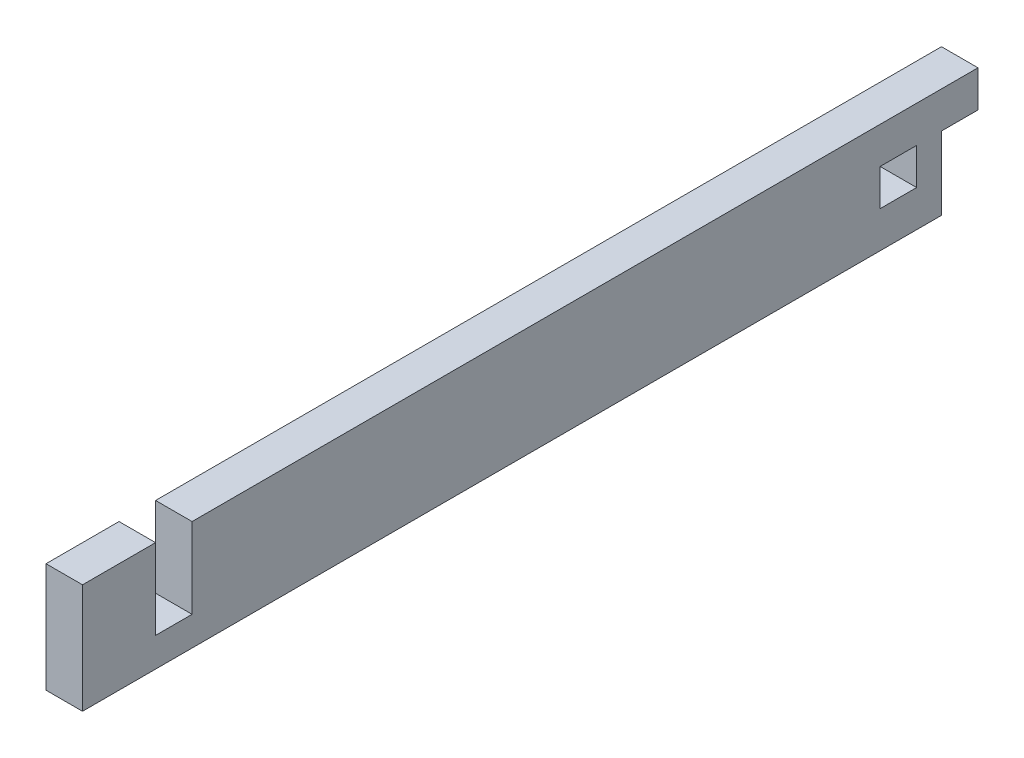
from build123d import *

# Parameters (mm, degrees)
BOSS_EXTRUDE1_DEPTH = 19.05
SKETCH2_W           = 43.434
SKETCH2_H           = 13.97
MOTOR_HOLE_DEPTH    = 19.05
SKETCH3_W           = 6.35
SKETCH3_H           = 12.7
CUT_EXTRUDE2_DEPTH  = 36.941
SKETCH5_W           = 6.35
SKETCH5_H           = 13.97
SKETCH5_H_2         = 6.35
CUT_EXTRUDE6_DEPTH  = 36.941
SKETCH7_W           = 45.976326486
SKETCH7_H           = 159.787423729
CUT_EXTRUDE7_DEPTH  = 20.05


with BuildPart() as part:
    # Sketch1 → Boss-Extrude1 (new body)
    with BuildSketch(Plane(origin=(0, 0, 0), x_dir=(1, 0, 0), z_dir=(0, 1, 0))):
        Polygon((-10.033, 66.167), (-11.6205, 66.167), (-11.6205, 76.835), (-17.9705, 76.835), (-17.9705, -78.867), (-11.6205, -78.867), (-11.6205, -66.167), (11.6205, -66.167), (11.6205, -78.867), (17.9705, -78.867), (17.9705, 76.835), (11.6205, 76.835), (11.6205, 66.167), (10.033, 66.167), (10.033, 59.817), (11.6205, 59.817), (11.6205, -59.817), (-11.6205, -59.817), (-11.6205, 59.817), (-10.033, 59.817), align=None)
    extrude(amount=BOSS_EXTRUDE1_DEPTH)

    # Sketch2 → Motor Hole (cut)
    with BuildSketch(Plane.ZY.offset(17.9705)):
        with Locations((29.972, 12.065)):
            Rectangle(SKETCH2_W, SKETCH2_H)
    extrude(amount=-MOTOR_HOLE_DEPTH, mode=Mode.SUBTRACT)

    # Sketch3 → Cut-Extrude2 (cut, through all)
    with BuildSketch(Plane.ZY.offset(17.9705)):
        with Locations((-73.66, 6.35)):
            Rectangle(SKETCH3_W, SKETCH3_H)
    extrude(amount=-CUT_EXTRUDE2_DEPTH, mode=Mode.SUBTRACT)

    # Sketch5 → Cut-Extrude6 (cut, through all)
    with BuildSketch(Plane.ZY.offset(17.9705)):
        with Locations((62.992, 12.065)):
            Rectangle(SKETCH5_W, SKETCH5_H)
        with Locations((-62.992, 9.525)):
            Rectangle(SKETCH5_W, SKETCH5_H_2)
    extrude(amount=-CUT_EXTRUDE6_DEPTH, mode=Mode.SUBTRACT)

    # Sketch7 → Cut-Extrude7 (cut, through all)
    with BuildSketch(Plane(origin=(0, 0, 0), x_dir=(1, 0, 0), z_dir=(0, 1, 0))):
        with Locations((-11.367663243, 1.026711865)):
            Rectangle(SKETCH7_W, SKETCH7_H)
    extrude(amount=CUT_EXTRUDE7_DEPTH, mode=Mode.SUBTRACT)


solid = part.part
